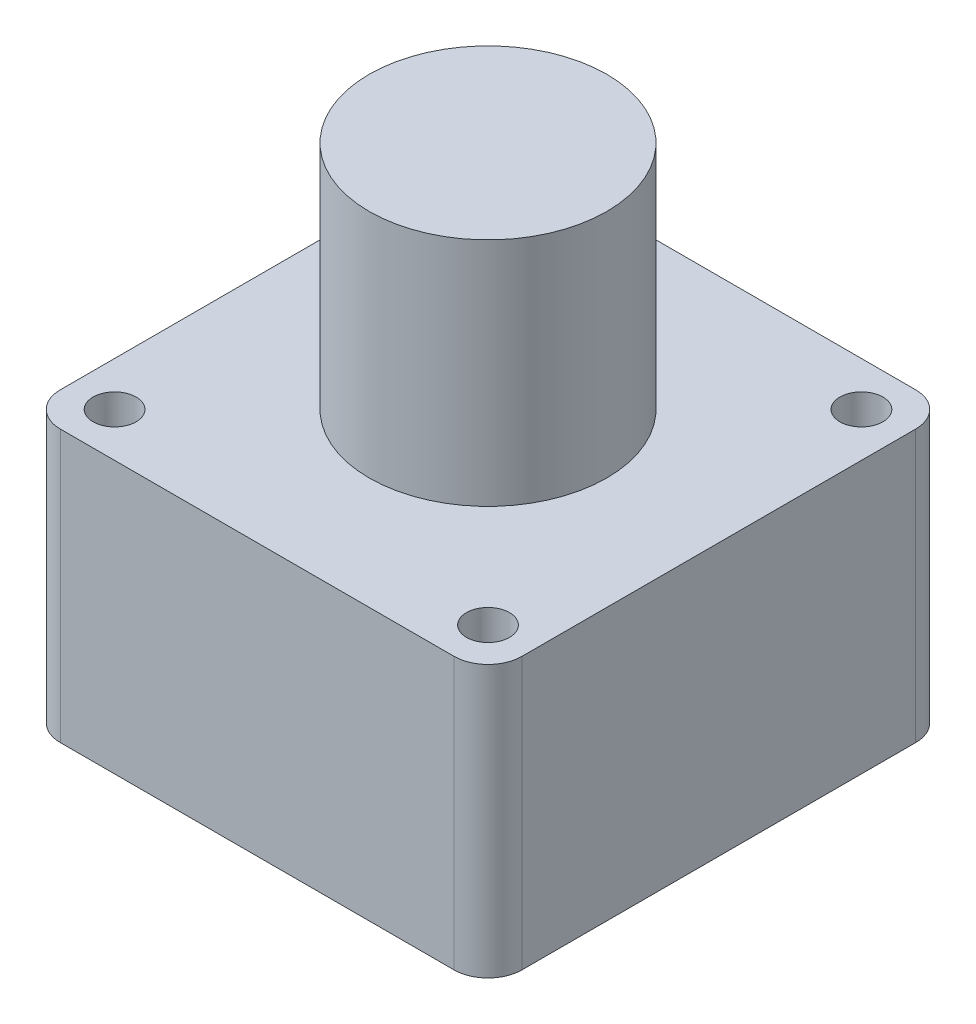
from build123d import *

# Parameters (mm, degrees)
BOSS_EXTRUDE1_DEPTH = 40
SKETCH2_R           = 17.5
BOSS_EXTRUDE2_DEPTH = 34
CUT_EXTRUDE1_REACH  = 42
SKETCH3_R           = 3.167479455


with BuildPart() as part:
    # Sketch1 → Boss-Extrude1 (new body)
    with BuildSketch(Plane(origin=(0, 0, 0), x_dir=(1, 0, 0), z_dir=(0, 1, 0))):
        with BuildLine():
            Line((-29, 34), (29, 34))
            ThreePointArc((29, 34), (32.535533906, 32.535533906), (34, 29))
            Line((34, 29), (34, -29))
            ThreePointArc((34, -29), (32.535533906, -32.535533906), (29, -34))
            Line((29, -34), (-29, -34))
            ThreePointArc((-29, -34), (-32.535533906, -32.535533906), (-34, -29))
            Line((-34, -29), (-34, 29))
            ThreePointArc((-34, 29), (-32.535533906, 32.535533906), (-29, 34))
        make_face()
    extrude(amount=BOSS_EXTRUDE1_DEPTH)

    # Sketch2 → Boss-Extrude2 (add)
    with BuildSketch(Plane(origin=(0, 40, 0), x_dir=(1, 0, 0), z_dir=(0, 1, 0))):
        Circle(SKETCH2_R)
    extrude(amount=BOSS_EXTRUDE2_DEPTH)

    # Sketch3 → Cut-Extrude1 (cut, up to next)
    with BuildSketch(Plane(origin=(0, 40, 0), x_dir=(1, 0, 0), z_dir=(0, 1, 0)), mode=Mode.PRIVATE) as cut_extrude1_sk1:
        with Locations((-27.5, 27.5)):
            Circle(SKETCH3_R)
    cut_extrude1_tool1 = extrude(cut_extrude1_sk1.sketch, amount=-CUT_EXTRUDE1_REACH, mode=Mode.PRIVATE) & part.part
    add(cut_extrude1_tool1.solids().sort_by_distance((-27.5, 40, -27.5))[0], mode=Mode.SUBTRACT)
    # Sketch3 → Cut-Extrude1 (cut, up to next)
    with BuildSketch(Plane(origin=(0, 40, 0), x_dir=(1, 0, 0), z_dir=(0, 1, 0)), mode=Mode.PRIVATE) as cut_extrude1_sk2:
        with Locations((-27.5, -27.5)):
            Circle(SKETCH3_R)
    cut_extrude1_tool2 = extrude(cut_extrude1_sk2.sketch, amount=-CUT_EXTRUDE1_REACH, mode=Mode.PRIVATE) & part.part
    add(cut_extrude1_tool2.solids().sort_by_distance((-27.5, 40, 27.5))[0], mode=Mode.SUBTRACT)
    # Sketch3 → Cut-Extrude1 (cut, up to next)
    with BuildSketch(Plane(origin=(0, 40, 0), x_dir=(1, 0, 0), z_dir=(0, 1, 0)), mode=Mode.PRIVATE) as cut_extrude1_sk3:
        with Locations((27.5, -27.5)):
            Circle(SKETCH3_R)
    cut_extrude1_tool3 = extrude(cut_extrude1_sk3.sketch, amount=-CUT_EXTRUDE1_REACH, mode=Mode.PRIVATE) & part.part
    add(cut_extrude1_tool3.solids().sort_by_distance((27.5, 40, 27.5))[0], mode=Mode.SUBTRACT)
    # Sketch3 → Cut-Extrude1 (cut, up to next)
    with BuildSketch(Plane(origin=(0, 40, 0), x_dir=(1, 0, 0), z_dir=(0, 1, 0)), mode=Mode.PRIVATE) as cut_extrude1_sk4:
        with Locations((27.5, 27.5)):
            Circle(SKETCH3_R)
    cut_extrude1_tool4 = extrude(cut_extrude1_sk4.sketch, amount=-CUT_EXTRUDE1_REACH, mode=Mode.PRIVATE) & part.part
    add(cut_extrude1_tool4.solids().sort_by_distance((27.5, 40, -27.5))[0], mode=Mode.SUBTRACT)


solid = part.part
